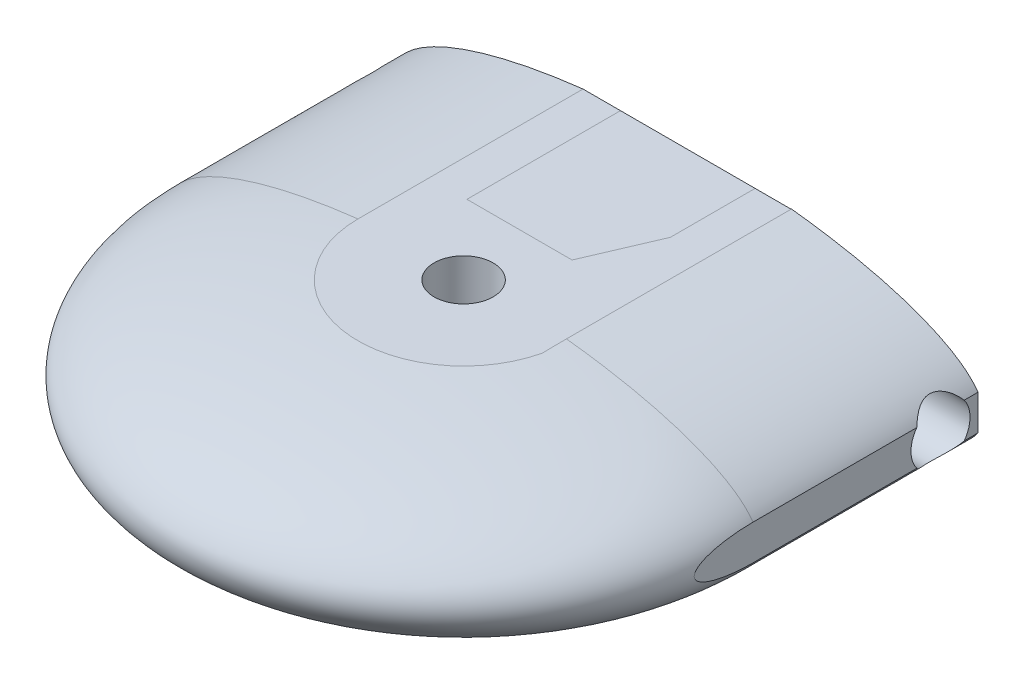
from build123d import *

# Parameters (mm, degrees)
SKETCH1_R                = 28.575
SKETCH1_R_2              = 26.9875
BOSS_EXTRUDE1_DEPTH      = 67
BOSS_EXTRUDE2_DEPTH      = 76.2
BOSS_EXTRUDE2_DEPTH_BACK = 76.2
SKETCH4_R                = 25.4
CUT_EXTRUDE1_DEPTH       = 76.2
SKETCH7_W                = 2.71552133
SKETCH7_H                = 38.476912095
CUT_EXTRUDE2_DEPTH       = 10.2
SKETCH11_R               = 5
CUT_EXTRUDE4_DEPTH       = 80
CUT_EXTRUDE6_START       = -80
SKETCH13_R               = 5
CUT_EXTRUDE6_DEPTH       = 164
CUT_EXTRUDE5_DEPTH       = 116
CUT_EXTRUDE5_DEPTH_BACK  = 30
SKETCH12_W               = 109.542334242
SKETCH12_H               = 190.943936144
SKETCH14_W               = 10.33553104
SKETCH14_H               = 18.41327722
SKETCH14_W_2             = 35.291047333
SKETCH14_H_2             = 4.611114104
CUT_EXTRUDE7_DEPTH       = 80
SKETCH15_W               = 22.796475904
SKETCH15_H               = 28.016727608
BOSS_EXTRUDE3_DEPTH      = 26


with BuildPart() as part:
    # Sketch1 → Boss-Extrude1 (new body)
    with BuildSketch(Plane(origin=(0, 0, 0), x_dir=(1, 0, 0), z_dir=(0, 1, 0))):
        Circle(SKETCH1_R)
        Circle(SKETCH1_R_2, mode=Mode.SUBTRACT)
    extrude(amount=BOSS_EXTRUDE1_DEPTH)

    # Sketch2 → Boss-Extrude2 (add, two sides: drawn at the far end of the back side and taken through both)
    with BuildSketch(Plane.XY.offset(-BOSS_EXTRUDE2_DEPTH_BACK)):
        with BuildLine():
            add(Edge.make_bspline(
                [(0, 48.5), (-50, 48.5), (-50, 33.5)],
                knots=[1.570796327, 1.570796327, 1.570796327, 3.141592654, 3.141592654, 3.141592654], degree=2, weights=[1, 0.707106781, 1]))
            add(Edge.make_bspline(
                [(-50, 33.5), (-50, 18.5), (0, 18.5)],
                knots=[3.141592654, 3.141592654, 3.141592654, 4.71238898, 4.71238898, 4.71238898], degree=2, weights=[1, 0.707106781, 1]))
            add(Edge.make_bspline(
                [(0, 18.5), (50, 18.5), (50, 33.5)],
                knots=[4.71238898, 4.71238898, 4.71238898, 6.283185307, 6.283185307, 6.283185307], degree=2, weights=[1, 0.707106781, 1]))
            add(Edge.make_bspline(
                [(50, 33.5), (50, 48.5), (0, 48.5)],
                knots=[0, 0, 0, 1.570796327, 1.570796327, 1.570796327], degree=2, weights=[1, 0.707106781, 1]))
        make_face()
    extrude(amount=BOSS_EXTRUDE2_DEPTH + BOSS_EXTRUDE2_DEPTH_BACK)

    # Sketch4 → Cut-Extrude1 (cut)
    with BuildSketch(Plane(origin=(0, 67, 0), x_dir=(1, 0, 0), z_dir=(0, 1, 0))):
        Circle(SKETCH4_R)
    extrude(amount=-CUT_EXTRUDE1_DEPTH, mode=Mode.SUBTRACT)

    # Sketch7 → Cut-Extrude2 (cut)
    with BuildSketch(Plane(origin=(0, 67, 0), x_dir=(1, 0, 0), z_dir=(0, 1, 0))):
        with Locations((28.578000506, 1.313730045)):
            Rectangle(SKETCH7_W, SKETCH7_H)
    extrude(amount=-CUT_EXTRUDE2_DEPTH, mode=Mode.SUBTRACT)

    # Sketch10 → Revolve2 (revolve)
    with BuildSketch(Plane.XY.offset(76.2)):
        with BuildLine():
            add(Edge.make_bspline(
                [(20.800996577, 47.140332427), (10.894250248, 48.5), (0, 48.5)],
                knots=[1.141732213, 1.141732213, 1.141732213, 1.570796327, 1.570796327, 1.570796327], degree=2, weights=[1, 0.977076122, 1]))
            Line((0, 48.5), (0, 18.5))
            add(Edge.make_bspline(
                [(0, 18.5), (10.894250248, 18.5), (20.800996577, 19.859667573)],
                knots=[4.71238898, 4.71238898, 4.71238898, 5.141453094, 5.141453094, 5.141453094], degree=2, weights=[1, 0.977076122, 1]))
            add(Edge.make_bspline(
                [(20.800996577, 19.859667573), (50, 23.867132465), (50, 33.5)],
                knots=[5.141453094, 5.141453094, 5.141453094, 6.283185307, 6.283185307, 6.283185307], degree=2, weights=[1, 0.841433281, 1]))
            add(Edge.make_bspline(
                [(50, 33.5), (50, 43.132867535), (20.800996577, 47.140332427)],
                knots=[0, 0, 0, 1.141732213, 1.141732213, 1.141732213], degree=2, weights=[1, 0.841433281, 1]))
        make_face()
    revolve2 = revolve(axis=Axis((0, 48.5, 76.2), (0, -1, 0)))

    # Mirror2: Revolve2 across plane
    add(revolve2.mirror(Plane.XY))

    # Sketch11 → Cut-Extrude4 (cut)
    with BuildSketch(Plane(origin=(0, 67, 0), x_dir=(1, 0, 0), z_dir=(0, 1, 0))):
        with Locations((0, -76.2)):
            Circle(SKETCH11_R)
        with Locations((0, 76.2)):
            Circle(SKETCH11_R)
    extrude(amount=-CUT_EXTRUDE4_DEPTH, mode=Mode.SUBTRACT)

    # Sketch13 → Cut-Extrude6 (cut)
    with BuildSketch(Plane(origin=(0, 0, 0), x_dir=(0, 0, -1), z_dir=(1, 0, 0)).offset(CUT_EXTRUDE6_START)):
        with Locations((-44.45, 33.5)):
            Circle(SKETCH13_R)
    cut_extrude6 = extrude(amount=CUT_EXTRUDE6_DEPTH, mode=Mode.SUBTRACT)

    # Mirror3: Cut-Extrude6 across plane
    add(cut_extrude6.mirror(Plane.XY), mode=Mode.SUBTRACT)

    # Sketch12 → Cut-Extrude5 (cut, two sides: drawn at the far end of the back side and taken through both)
    with BuildSketch(Plane(origin=(0, 0, 0), x_dir=(1, 0, 0), z_dir=(0, 1, 0)).offset(-CUT_EXTRUDE5_DEPTH_BACK)):
        with Locations((-1.20108686, 57.371968072)):
            Rectangle(SKETCH12_W, SKETCH12_H)
    extrude(amount=CUT_EXTRUDE5_DEPTH + CUT_EXTRUDE5_DEPTH_BACK, mode=Mode.SUBTRACT)

    # Sketch14 → Cut-Extrude7 (cut)
    with BuildSketch(Plane(origin=(0, 0, 38.1), x_dir=(-1, 0, 0), z_dir=(0, 0, -1))):
        with BuildLine():
            add(Edge.make_bspline(
                [(17.877901796, 47.508363804), (9.244524398, 48.5), (0, 48.5)],
                knots=[4.346737228, 4.346737228, 4.346737228, 4.71238898, 4.71238898, 4.71238898], degree=2, weights=[1, 0.98333385, 1]))
            add(Edge.make_bspline(
                [(0, 48.5), (-8.987908235, 48.5), (-17.413145537, 47.560953475)],
                knots=[4.71238898, 4.71238898, 4.71238898, 5.068106346, 5.068106346, 5.068106346], degree=2, weights=[1, 0.984224796, 1]))
            Line((-17.413145537, 47.560953475), (-17.413145537, 47.508363804))
            Line((-17.413145537, 47.508363804), (17.877901796, 47.508363804))
        make_face()
        with Locations((54.16776552, 33.527616854)):
            Rectangle(SKETCH14_W, SKETCH14_H)
        with Locations((-54.16776552, 33.527616854)):
            Rectangle(SKETCH14_W, SKETCH14_H)
        with Locations((0.232378129, 17.186079144)):
            Rectangle(SKETCH14_W_2, SKETCH14_H_2)
    extrude(amount=-CUT_EXTRUDE7_DEPTH, mode=Mode.SUBTRACT)


with BuildPart() as body_2:
    # Sketch15 → Boss-Extrude3 (new body)
    with BuildSketch(Plane(origin=(0, 0, 38.1), x_dir=(-1, 0, 0), z_dir=(0, 0, -1))):
        with Locations((0.13489039, 33.5)):
            Rectangle(SKETCH15_W, SKETCH15_H)
    extrude(amount=-BOSS_EXTRUDE3_DEPTH)


solid = Compound([part.part, body_2.part])
